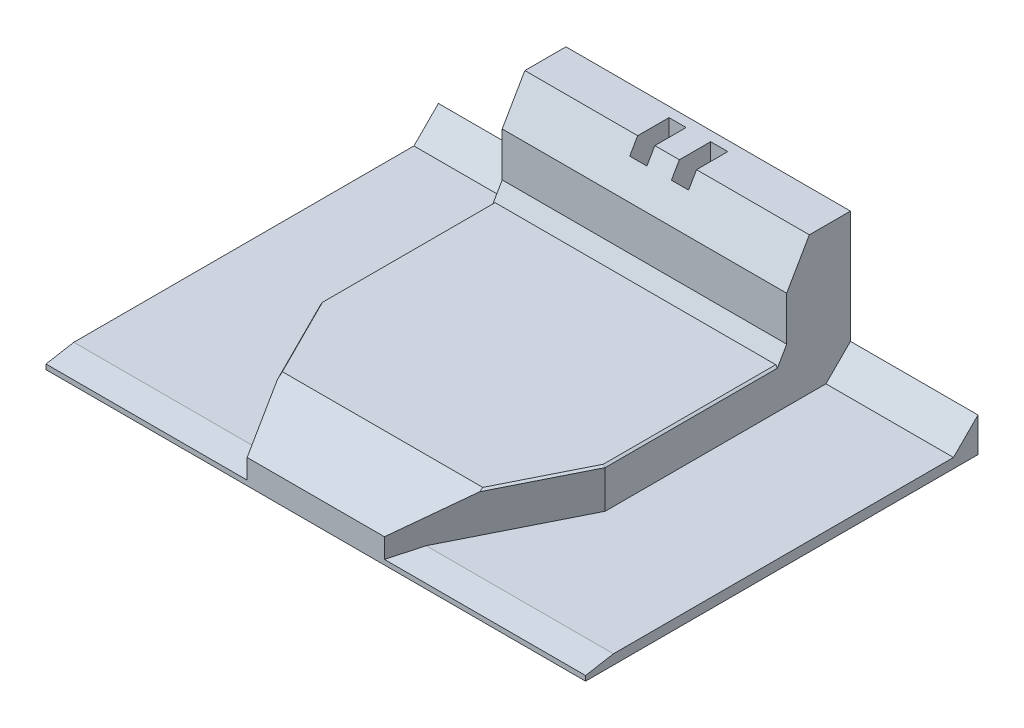
from build123d import *

# Parameters (mm, degrees)
SKETCH_1_W                  = 110
SKETCH_1_H                  = 80
EXTRUDE_1_DEPTH             = 2
SKETCH_2_W                  = 58
SKETCH_2_H                  = 80
EXTRUDE_2_DEPTH             = 8
CUT_EXTRUDE_1_DEPTH         = 8
SKETCH_4_W                  = 58
SKETCH_4_H                  = 13
EXTRUDE_3_DEPTH             = 28
CHAMFER_1_SIZE              = 8
CHAMFER_1_SIZE2             = 4.618802154
CHAMFER_2_SIZE              = 5
CHAMFER_2_SIZE2             = 13.737387097
CHAMFER_3_SIZE              = 1
CHAMFER_3_SIZE2             = 5.67128182
EXTRUDE_5_REACH             = 28
EXTRUDE_5_DIRECTION_2_REACH = 86
SKETCH_5_W                  = 3.5
SKETCH_5_H                  = 8
CUT_EXTRUDE_2_DEPTH         = 31
SKETCH_6_W                  = 30
SKETCH_6_H                  = 20
CUT_EXTRUDE_3_DEPTH         = 9
SKETCH_7_W                  = 30
SKETCH_7_H                  = 3
EXTRUDE_4_DEPTH             = 4
SKETCH_8_W                  = 2.5
SKETCH_8_H                  = 3
CUT_EXTRUDE_4_DEPTH         = 0.2
SKETCH_10_R                 = 0.5
CUT_EXTRUDE_5_DEPTH         = 4
SKETCH_11_R                 = 0.5
CUT_EXTRUDE_6_DEPTH         = 4
CHAMFER_4_SIZE              = 3
CHAMFER_4_SIZE2             = 1.732050808
CHAMFER_5_SIZE              = 0.5
CHAMFER_5_SIZE2             = 0.288675135
CHAMFER_5_PART_2_SIZE       = 0.5
CHAMFER_5_PART_2_SIZE2      = 0.288675135
CHAMFER_5_PART_3_SIZE       = 0.5
CHAMFER_5_PART_3_SIZE2      = 0.288675135
CUT_EXTRUDE_7_DEPTH         = 8
SKETCH_14_W                 = 5
SKETCH_14_H                 = 10
CUT_EXTRUDE_8_DEPTH         = 3


with BuildPart() as part:
    # 草图1 → 凸台-拉伸1 (new body)
    with BuildSketch(Plane(origin=(0, 0, 0), x_dir=(1, 0, 0), z_dir=(0, 1, 0))):
        Rectangle(SKETCH_1_W, SKETCH_1_H)
    extrude(amount=EXTRUDE_1_DEPTH)

    # 草图2 → 凸台-拉伸2 (add)
    with BuildSketch(Plane(origin=(0, 2, 0), x_dir=(1, 0, 0), z_dir=(0, 1, 0))):
        Rectangle(SKETCH_2_W, SKETCH_2_H)
    extrude(amount=EXTRUDE_2_DEPTH)

    # 草图3 → 切除-拉伸1 (cut)
    with BuildSketch(Plane(origin=(0, 10, 0), x_dir=(1, 0, 0), z_dir=(0, 1, 0))):
        Polygon((-14, -40), (-29, -10), (-29, -40), align=None)
        Polygon((29, -40), (14, -40), (29, -10), align=None)
    extrude(amount=-CUT_EXTRUDE_1_DEPTH, mode=Mode.SUBTRACT)

    # 草图4 → 凸台-拉伸3 (add)
    with BuildSketch(Plane(origin=(0, 2, 0), x_dir=(1, 0, 0), z_dir=(0, 1, 0))):
        with Locations((0, 33.5)):
            Rectangle(SKETCH_4_W, SKETCH_4_H)
    extrude(amount=EXTRUDE_3_DEPTH)

    # 倒角1
    chamfer_1_edges = [part.edges().sort_by_distance(p)[0] for p in [
        (0, 30, -27),
    ]]
    chamfer_1_side = [part.faces().sort_by_distance(p)[0] for p in [
        (0, 20, -27),
    ]]
    chamfer(chamfer_1_edges, length=CHAMFER_1_SIZE, length2=CHAMFER_1_SIZE2, reference=chamfer_1_side[0])

    # 倒角2
    chamfer_2_edges = [part.edges().sort_by_distance(p)[0] for p in [
        (0, 10, 40),
    ]]
    chamfer_2_side = [part.faces().sort_by_distance(p)[0] for p in [
        (0, 3.522522523, 40),
    ]]
    chamfer(chamfer_2_edges, length=CHAMFER_2_SIZE, length2=CHAMFER_2_SIZE2, reference=chamfer_2_side[0])

    # 倒角3
    chamfer_3_edges = [part.edges().sort_by_distance(p)[0] for p in [
        (34.5, 2, 40),
        (-34.5, 2, 40),
    ]]
    chamfer_3_side = [part.faces().sort_by_distance(p)[0] for p in [
        (0, 1.690789474, 40),
    ]]
    chamfer(chamfer_3_edges, length=CHAMFER_3_SIZE, length2=CHAMFER_3_SIZE2, reference=chamfer_3_side[0])

    # 凸台-拉伸5: up to this face of the body (flat: up to its plane)
    extrude_5_end = Plane(part.part.faces().sort_by_distance((55, 0.987971654, -0.687592684))[0])
    # 草图12 → 凸台-拉伸5 (add, up to the picked face)
    with BuildSketch(Plane(origin=(29, 0, 0), x_dir=(0, 0, -1), z_dir=(1, 0, 0)), mode=Mode.PRIVATE) as extrude_5_sk1:
        Polygon((40, 2), (40, 7), (35, 2), align=None)
    extrude_5_tool1 = split(extrude(extrude_5_sk1.sketch, amount=EXTRUDE_5_REACH, mode=Mode.PRIVATE), bisect_by=extrude_5_end, keep=Keep.BOTH, mode=Mode.PRIVATE)
    add(extrude_5_tool1.solids().sort_by_distance((29, 3.666667, -38.333333))[0])

    # 凸台-拉伸5 direction 2: up to this face of the body (flat: up to its plane)
    extrude_5_direction_2_end = Plane(part.part.faces().sort_by_distance((-55, 0.987971654, -0.687592684))[0])
    # 草图12 → 凸台-拉伸5 direction 2 (add, up to the picked face)
    with BuildSketch(Plane(origin=(29, 0, 0), x_dir=(0, 0, -1), z_dir=(1, 0, 0)), mode=Mode.PRIVATE) as extrude_5_direction_2_sk1:
        Polygon((40, 2), (40, 7), (35, 2), align=None)
    extrude_5_direction_2_tool1 = split(extrude(extrude_5_direction_2_sk1.sketch, amount=-EXTRUDE_5_DIRECTION_2_REACH, mode=Mode.PRIVATE), bisect_by=extrude_5_direction_2_end, keep=Keep.BOTH, mode=Mode.PRIVATE)
    add(extrude_5_direction_2_tool1.solids().sort_by_distance((29, 3.666667, -38.333333))[0])

    # 草图5 → 切除-拉伸2 (cut, through all)
    with BuildSketch(Plane.XZ):
        with Locations((-4.25, -34)):
            Rectangle(SKETCH_5_W, SKETCH_5_H)
        with Locations((4.25, -34)):
            Rectangle(SKETCH_5_W, SKETCH_5_H)
    extrude(amount=-CUT_EXTRUDE_2_DEPTH, mode=Mode.SUBTRACT)

    # 草图6 → 切除-拉伸3 (cut)
    with BuildSketch(Plane.XZ):
        with Locations((0, -28)):
            Rectangle(SKETCH_6_W, SKETCH_6_H)
    extrude(amount=-CUT_EXTRUDE_3_DEPTH, mode=Mode.SUBTRACT)

    # 草图7 → 凸台-拉伸4 (add)
    with BuildSketch(Plane.XZ.offset(-9)):
        with Locations((0, -27.5)):
            Rectangle(SKETCH_7_W, SKETCH_7_H)
    extrude(amount=EXTRUDE_4_DEPTH)

    # 草图8 → 切除-拉伸4 (cut)
    with BuildSketch(Plane.XZ.offset(-5)):
        with Locations((-4.25, -27.5)):
            Rectangle(SKETCH_8_W, SKETCH_8_H)
        with Locations((4.25, -27.5)):
            Rectangle(SKETCH_8_W, SKETCH_8_H)
    extrude(amount=-CUT_EXTRUDE_4_DEPTH, mode=Mode.SUBTRACT)

    # 草图10 → 切除-拉伸5 (cut)
    with BuildSketch(Plane.XZ.offset(-5)):
        with Locations((-8, -27.5)):
            Circle(SKETCH_10_R)
        with Locations((8, -27.5)):
            Circle(SKETCH_10_R)
        with Locations((0, -27.5)):
            Circle(SKETCH_10_R)
    extrude(amount=-CUT_EXTRUDE_5_DEPTH, mode=Mode.SUBTRACT)

    # 草图11 → 切除-拉伸6 (cut)
    with BuildSketch(Plane(origin=(0, 0, -40), x_dir=(-1, 0, 0), z_dir=(0, 0, -1))):
        with Locations((-52.5, 2)):
            Circle(SKETCH_11_R)
        with Locations((52.5, 2)):
            Circle(SKETCH_11_R)
        with Locations((-27, 28)):
            Circle(SKETCH_11_R)
        with Locations((27, 28)):
            Circle(SKETCH_11_R)
    extrude(amount=-CUT_EXTRUDE_6_DEPTH, mode=Mode.SUBTRACT)

    # 倒角4
    chamfer_4_edges = [part.edges().sort_by_distance(p)[0] for p in [
        (0, 10, -27),
    ]]
    chamfer_4_side = [part.faces().sort_by_distance(p)[0] for p in [
        (0, 16, -27),
    ]]
    chamfer(chamfer_4_edges, length=CHAMFER_4_SIZE, length2=CHAMFER_4_SIZE2, reference=chamfer_4_side[0])

    # 倒角5
    chamfer_5_edges = [part.edges().sort_by_distance(p)[0] for p in [
        (29, 10, -7.633974596),
        (24.934346774, 10, 18.131306451),
    ]]
    chamfer_5_side = [part.faces().sort_by_distance(p)[0] for p in [
        (0, 10, -0.444462332),
    ]]
    chamfer(chamfer_5_edges, length=CHAMFER_5_SIZE, length2=CHAMFER_5_SIZE2, reference=chamfer_5_side[0])

    # 倒角5 part 2
    chamfer_5_part_2_edges = [part.edges().sort_by_distance(p)[0] for p in [
        (-29, 10, -7.633974596),
    ]]
    chamfer_5_part_2_side = [part.faces().sort_by_distance(p)[0] for p in [
        (-29, 17.5, -27.573061951),
    ]]
    chamfer(chamfer_5_part_2_edges, length=CHAMFER_5_PART_2_SIZE, length2=CHAMFER_5_PART_2_SIZE2, reference=chamfer_5_part_2_side[0])

    # 倒角5 part 3
    chamfer_5_part_3_edges = [part.edges().sort_by_distance(p)[0] for p in [
        (-24.934346774, 10, 18.131306451),
    ]]
    chamfer_5_part_3_side = [part.faces().sort_by_distance(p)[0] for p in [
        (-22.269129124, 5.556709809, 23.461741751),
    ]]
    chamfer(chamfer_5_part_3_edges, length=CHAMFER_5_PART_3_SIZE, length2=CHAMFER_5_PART_3_SIZE2, reference=chamfer_5_part_3_side[0])

    # 草图13 → 切除-拉伸7 (cut)
    with BuildSketch(Plane.XZ):
        Polygon((27.5, -16), (-27.5, -16), (-27.5, 9.67128182), (-14.5, 30), (14.5, 30), (27.5, 9.67128182), align=None)
    extrude(amount=-CUT_EXTRUDE_7_DEPTH, mode=Mode.SUBTRACT)

    # 草图14 → 切除-拉伸8 (cut)
    with BuildSketch(Plane(origin=(0, 0, -40), x_dir=(-1, 0, 0), z_dir=(0, 0, -1))):
        Rectangle(SKETCH_14_W, SKETCH_14_H)
    extrude(amount=-CUT_EXTRUDE_8_DEPTH, mode=Mode.SUBTRACT)


solid = part.part
